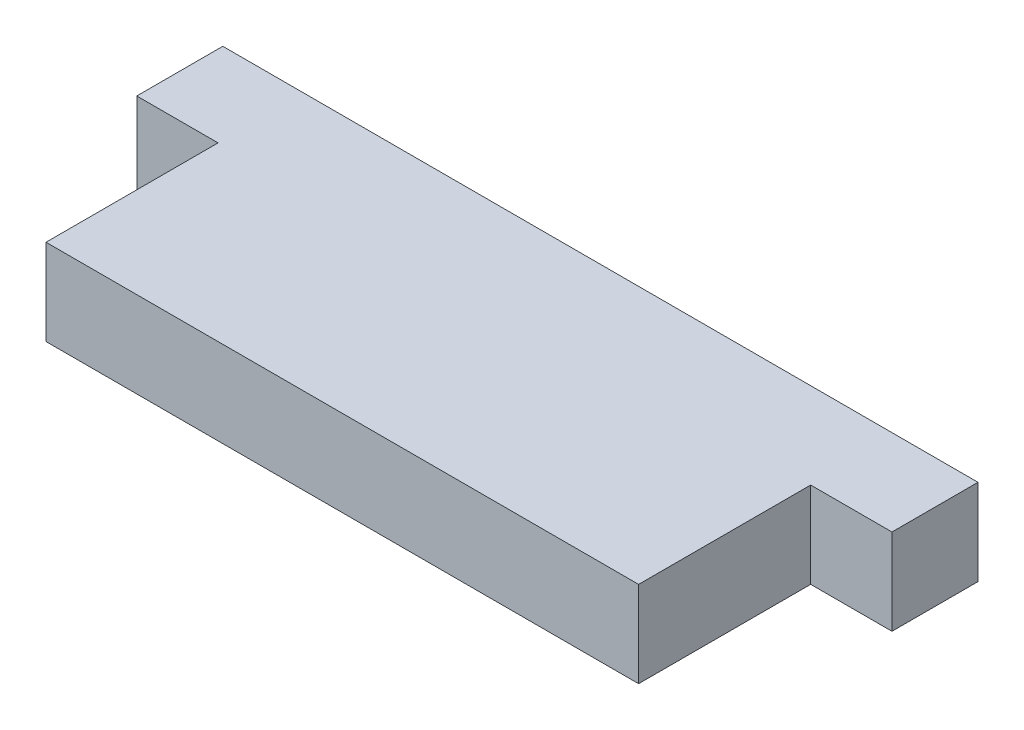
from build123d import *

# Parameters (mm, degrees)
BOSS_EXTRUDE1_DEPTH = 6.35


with BuildPart() as part:
    # Sketch1 → Boss-Extrude1 (new body)
    with BuildSketch(Plane(origin=(0, 0, 0), x_dir=(1, 0, 0), z_dir=(0, 1, 0))):
        Polygon((0, 0), (0, 12.7), (-6.0000896, 12.7), (-6.0000896, 19.05), (49.740089496, 19.05), (49.740089496, 12.7), (43.739999896, 12.7), (43.739999896, 0), align=None)
    extrude(amount=BOSS_EXTRUDE1_DEPTH)


solid = part.part
